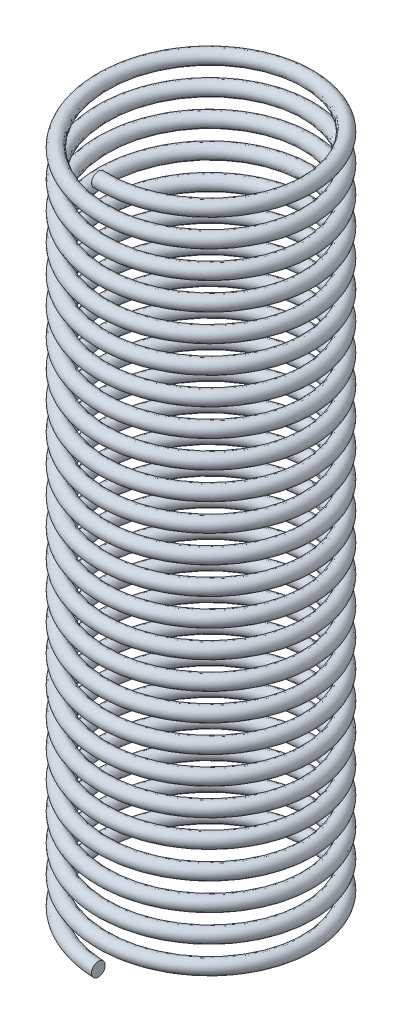
from build123d import *

# Parameters (mm, degrees)
SWEEP1_PITCH  = 20
SWEEP1_HEIGHT = 500
SWEEP1_RADIUS = 75
SKETCH2_R     = 5


with BuildPart() as part:
    # Sweep1: sweep along a helix
    with BuildLine() as sweep1_path:
        Helix(SWEEP1_PITCH, SWEEP1_HEIGHT, SWEEP1_RADIUS, center=(0, 0, 0), direction=(0, 1, 0), lefthand=True)
    # Sketch2 → Sweep1 (sweep)
    with BuildSketch(Plane(origin=(0, 0, 0), x_dir=(0, 0, -1), z_dir=(1, 0, 0))):
        with Locations((-75, 0)):
            Circle(SKETCH2_R)
    sweep(path=sweep1_path.line, is_frenet=True)


solid = part.part
